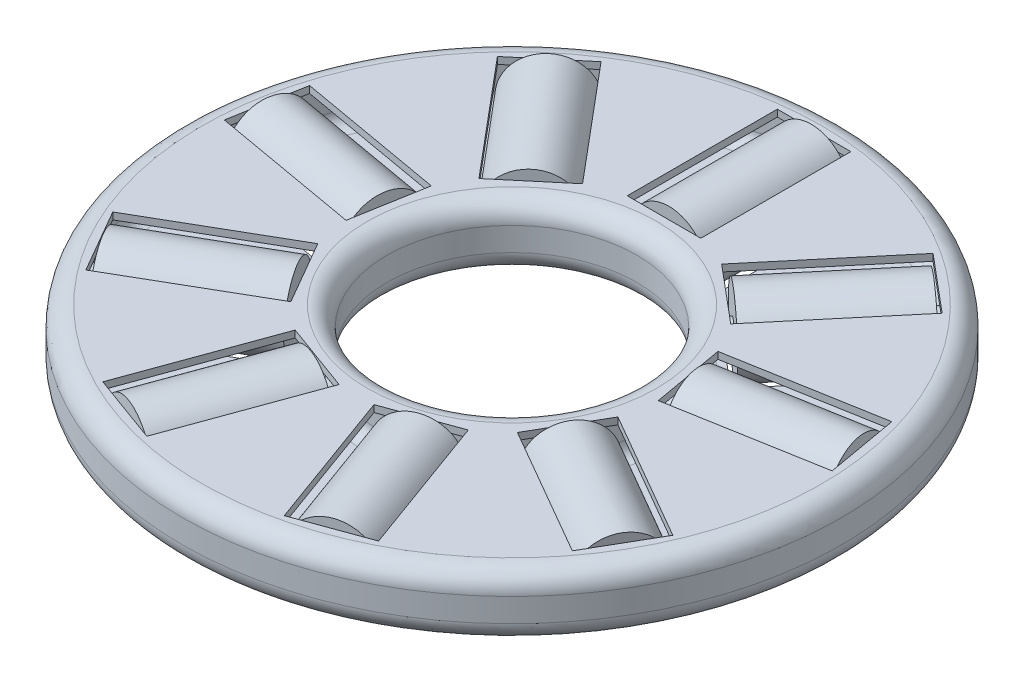
from build123d import *

# Parameters (mm, degrees)
SKETCH4_W          = 1.905
SKETCH4_H          = 3.8862
CUT_EXTRUDE1_DEPTH = 2.6256
SHELL1_T           = -0.1778
CIRPATTERN3_COUNT  = 9
CIRPATTERN2_COUNT  = 9


with BuildPart() as part:
    # Sketch3 → Base-Revolve (revolve)
    with BuildSketch(Plane.XY):
        with BuildLine():
            Line((3.2385, 0), (8.5344, 0))
            Line((8.5344, 0), (8.5344, 0.3048))
            ThreePointArc((8.5344, 0.3048), (8.385610245, 0.664010245), (8.0264, 0.8128))
            Line((8.0264, 0.8128), (3.7465, 0.8128))
            ThreePointArc((3.7465, 0.8128), (3.387289755, 0.664010245), (3.2385, 0.3048))
            Line((3.2385, 0.3048), (3.2385, 0))
        make_face()
    base_revolve = revolve(axis=Axis((0, 0, 0), (0, 1, 0)))

    # Mirror3: Base-Revolve across plane
    add(base_revolve.mirror(Plane.ZX))

    # Sketch4 → Cut-Extrude1 (cut, through all)
    with BuildSketch(Plane(origin=(0, 0.8128, 0), x_dir=(-1, 0, 0), z_dir=(0, 1, 0))):
        with Locations((0, -5.8801)):
            Rectangle(SKETCH4_W, SKETCH4_H)
    cut_extrude1 = extrude(amount=-CUT_EXTRUDE1_DEPTH, mode=Mode.SUBTRACT)

    # Shell1
    shell1_openings = [part.faces().sort_by_distance(p)[0] for p in [
        (0.9525, 0, -5.8801),
        (0, 0, -3.937),
        (-0.9525, 0, -5.8801),
        (0, 0, -7.8232),
    ]]
    offset(amount=SHELL1_T, openings=shell1_openings, kind=Kind.INTERSECTION)

    # CirPattern3: Cut-Extrude1 ×9 about axis
    cirpattern3_axis = Axis((0, 0, 0), (0, 1, 0))
    for i in range(1, CIRPATTERN3_COUNT):
        add(cut_extrude1.rotate(cirpattern3_axis, i * 360 / CIRPATTERN3_COUNT), mode=Mode.SUBTRACT)

    # Sketch5 → Boss-Revolve2 (revolve)
    with BuildSketch(Plane(origin=(0, 0, 0), x_dir=(0, 0, -1), z_dir=(1, 0, 0))):
        Polygon((3.3782, 0), (8.4328, 0), (8.4328, -0.254), (7.747, -0.254), (7.747, -0.9906), (4.064, -0.9906), (4.064, -0.254), (3.3782, -0.254), align=None)
    boss_revolve2 = revolve(axis=Axis((0, 0, 0), (0, 0, -1)))

    # CirPattern2: Boss-Revolve2 ×9 about axis
    cirpattern2_axis = Axis((0, 0, 0), (0, 1, 0))
    for i in range(1, CIRPATTERN2_COUNT):
        add(boss_revolve2.rotate(cirpattern2_axis, i * 360 / CIRPATTERN2_COUNT))


solid = part.part
